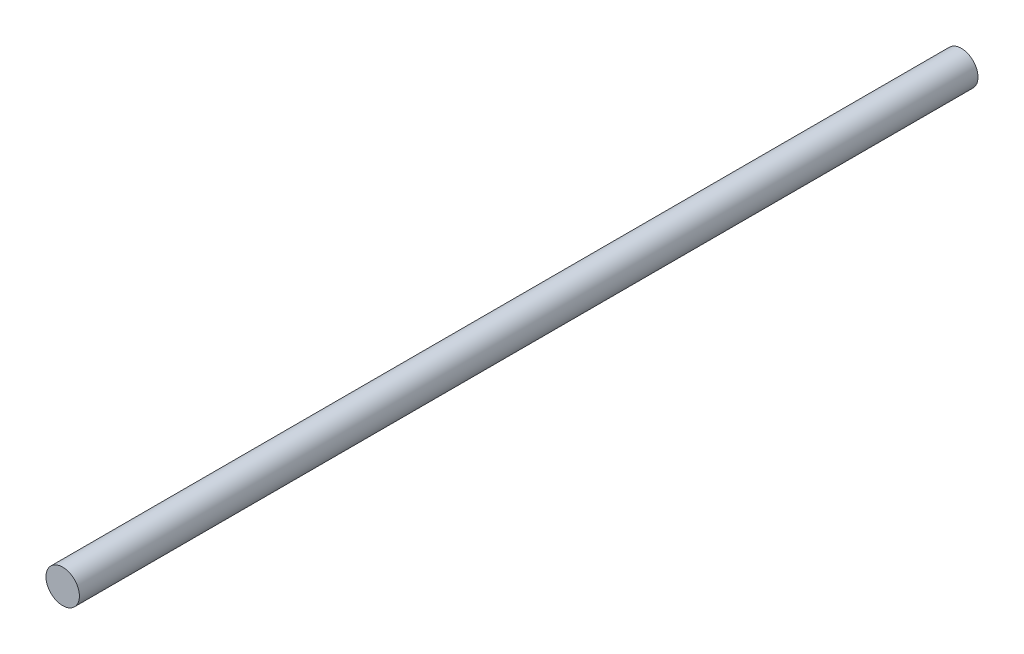
from build123d import *

# Parameters (mm, degrees)
SKETCH1_R           = 5
BOSS_EXTRUDE1_DEPTH = 269


with BuildPart() as part:
    # Sketch1 → Boss-Extrude1 (new body)
    with BuildSketch(Plane.XY):
        Circle(SKETCH1_R)
    extrude(amount=BOSS_EXTRUDE1_DEPTH)


solid = part.part
